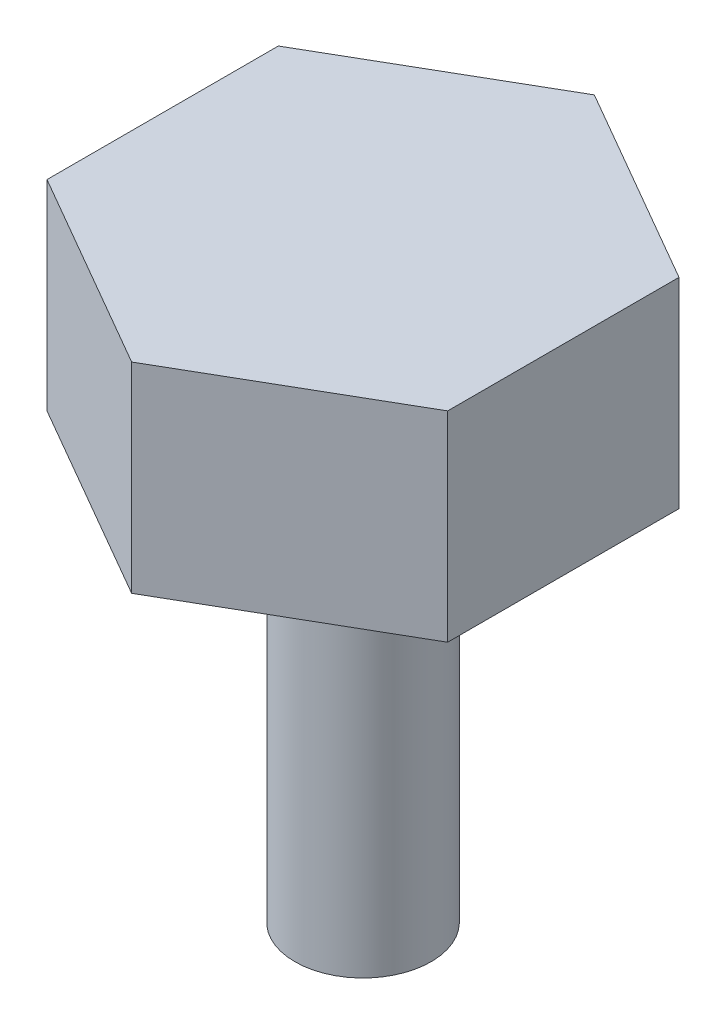
from build123d import *

# Parameters (mm, degrees)
SKETCH1_R           = 2.159
BOSS_EXTRUDE1_DEPTH = 12.7
BOSS_EXTRUDE2_DEPTH = 6.35


with BuildPart() as part:
    # Sketch1 → Boss-Extrude1 (new body)
    with BuildSketch(Plane(origin=(0, 0, 0), x_dir=(1, 0, 0), z_dir=(0, 1, 0))):
        Circle(SKETCH1_R)
    extrude(amount=BOSS_EXTRUDE1_DEPTH)

    # Sketch2 → Boss-Extrude2 (add)
    with BuildSketch(Plane(origin=(0, 12.7, 0), x_dir=(1, 0, 0), z_dir=(0, 1, 0))):
        Polygon((0, -7.332348419), (6.35, -3.666174209), (6.35, 3.666174209), (0, 7.332348419), (-6.35, 3.666174209), (-6.35, -3.666174209), align=None)
    extrude(amount=BOSS_EXTRUDE2_DEPTH)


solid = part.part
